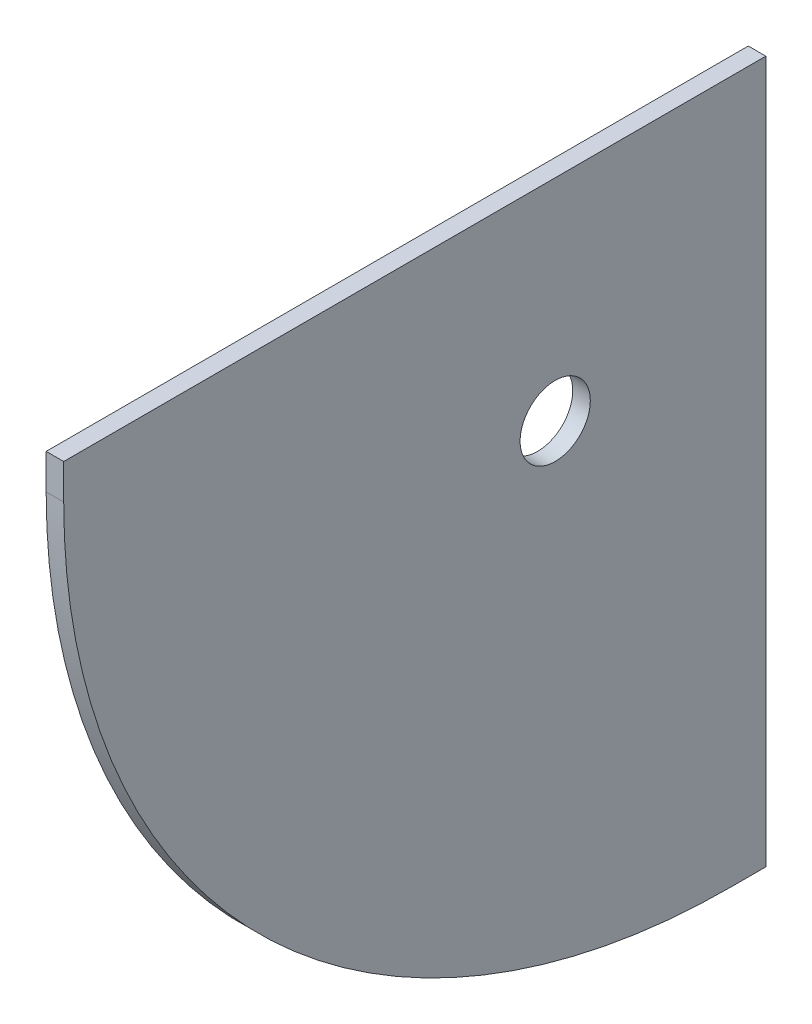
from build123d import *

# Parameters (mm, degrees)
SKETCH1_W           = 254
SKETCH1_H           = 254
BOSS_EXTRUDE1_DEPTH = 3.175
FILLET1_R           = 241.3
CUT_EXTRUDE1_REACH  = 8.35
SKETCH2_R           = 12.7


with BuildPart() as part:
    # Sketch1 → Boss-Extrude1 (new body, symmetric)
    with BuildSketch(Plane(origin=(0, 0, 0), x_dir=(0, 0, -1), z_dir=(1, 0, 0))):
        Rectangle(SKETCH1_W, SKETCH1_H)
    extrude(amount=BOSS_EXTRUDE1_DEPTH, both=True)

    # Fillet1
    fillet1_edges = [part.edges().sort_by_distance(p)[0] for p in [
        (0, -127, 127),
    ]]
    fillet(fillet1_edges, radius=FILLET1_R)

    # Sketch2 → Cut-Extrude1 (cut, up to next)
    with BuildSketch(Plane(origin=(3.175, 0, 0), x_dir=(0, 0, -1), z_dir=(1, 0, 0)), mode=Mode.PRIVATE) as cut_extrude1_sk1:
        with Locations((50.8, 50.8)):
            Circle(SKETCH2_R)
    cut_extrude1_tool1 = extrude(cut_extrude1_sk1.sketch, amount=-CUT_EXTRUDE1_REACH, mode=Mode.PRIVATE) & part.part
    add(cut_extrude1_tool1.solids().sort_by_distance((3.175, 50.8, -50.8))[0], mode=Mode.SUBTRACT)


solid = part.part
